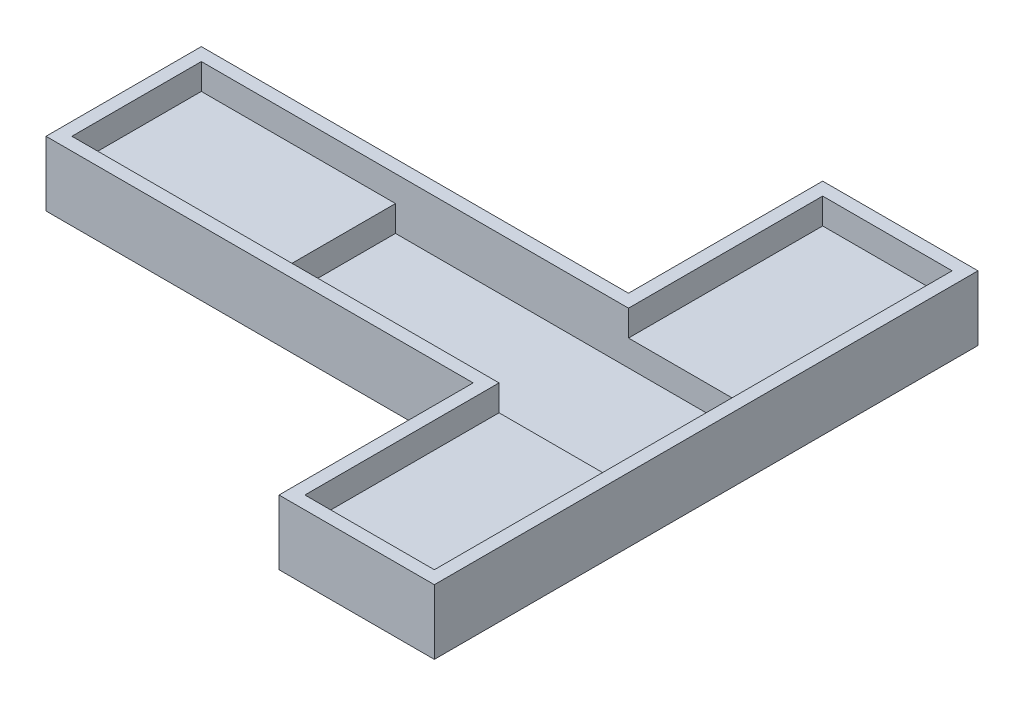
from build123d import *

# Parameters (mm, degrees)
SKETCH_2_W           = 43
SKETCH_2_H           = 10
SKETCH_2_W_2         = 10
SKETCH_2_H_2         = 15
EXTRUDE_1_DEPTH      = 1
EXTRUDE_2_DEPTH      = 4
EXTRUDE_2_DEPTH_BACK = 1
SKETCH_4_W           = 15
SKETCH_4_H           = 10
SKETCH_4_W_2         = 10
SKETCH_4_H_2         = 15
EXTRUDE_3_DEPTH      = 2


with BuildPart() as part:
    # 草图2 → 凸台-拉伸1 (new body)
    with BuildSketch(Plane(origin=(0, 0, 0), x_dir=(1, 0, 0), z_dir=(0, 1, 0))):
        with Locations((-7.5, 0)):
            Rectangle(SKETCH_2_W, SKETCH_2_H)
        with Locations((9, 12.5)):
            Rectangle(SKETCH_2_W_2, SKETCH_2_H_2)
        with Locations((9, -12.5)):
            Rectangle(SKETCH_2_W_2, SKETCH_2_H_2)
    extrude(amount=EXTRUDE_1_DEPTH)

    # 草图3 → 凸台-拉伸2 (add, two sides)
    with BuildSketch(Plane(origin=(0, 1, 0), x_dir=(1, 0, 0), z_dir=(0, 1, 0))) as extrude_2_sk:
        Polygon((15, -21), (15, 21), (3, 21), (3, 6), (-30, 6), (-30, -6), (3, -6), (3, -21), align=None)
        Polygon((14, -20), (14, 20), (4, 20), (4, 5), (-29, 5), (-29, -5), (4, -5), (4, -20), align=None, mode=Mode.SUBTRACT)
    extrude(amount=EXTRUDE_2_DEPTH)
    extrude(extrude_2_sk.sketch, amount=-EXTRUDE_2_DEPTH_BACK)

    # 草图4 → 凸台-拉伸3 (add)
    with BuildSketch(Plane(origin=(0, 1, 0), x_dir=(1, 0, 0), z_dir=(0, 1, 0))):
        with Locations((-21.5, 0)):
            Rectangle(SKETCH_4_W, SKETCH_4_H)
        with Locations((9, 12.5)):
            Rectangle(SKETCH_4_W_2, SKETCH_4_H_2)
        with Locations((9, -12.5)):
            Rectangle(SKETCH_4_W_2, SKETCH_4_H_2)
    extrude(amount=EXTRUDE_3_DEPTH)


solid = part.part
